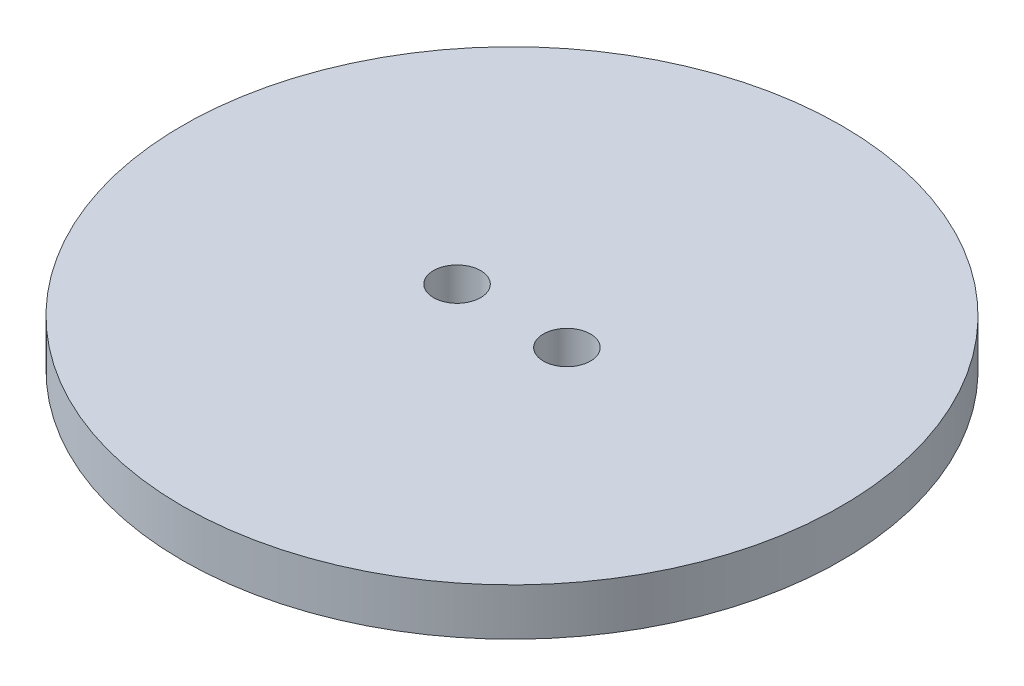
from build123d import *

# Parameters (mm, degrees)
ESQUISSE1_R        = 21
ESQUISSE1_R_2      = 1.5
BOSS_EXTRU_1_DEPTH = 3


with BuildPart() as part:
    # Esquisse1 → Boss.-Extru.1 (new body)
    with BuildSketch(Plane(origin=(0, 0, 0), x_dir=(1, 0, 0), z_dir=(0, 1, 0))):
        Circle(ESQUISSE1_R)
        with Locations((-3.5, 0)):
            Circle(ESQUISSE1_R_2, mode=Mode.SUBTRACT)
        with Locations((3.5, 0)):
            Circle(ESQUISSE1_R_2, mode=Mode.SUBTRACT)
    extrude(amount=BOSS_EXTRU_1_DEPTH)


solid = part.part
